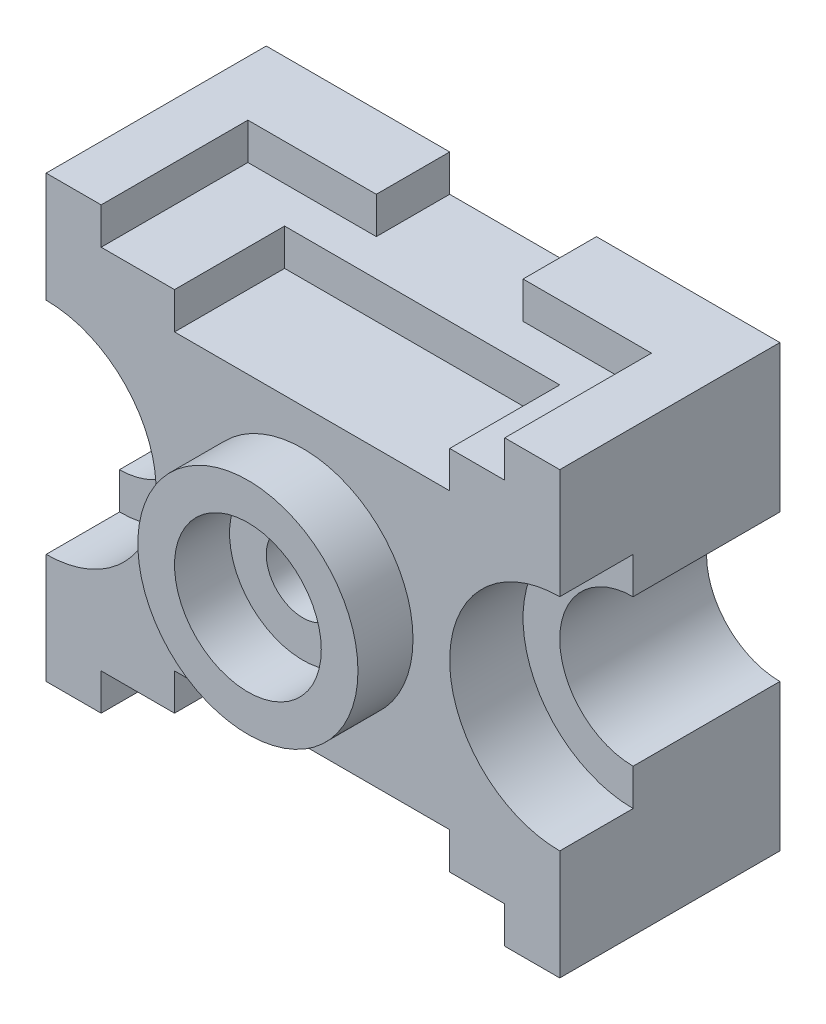
from build123d import *

# Parameters (mm, degrees)
BOSS_EXTRUDE1_DEPTH = 30
CUT_EXTRUDE7_DEPTH  = 20
SKETCH5_W           = 17.5
SKETCH5_H           = 10
BOSS_EXTRUDE2_DEPTH = 5
SKETCH6_W           = 40
SKETCH6_H           = 50
BOSS_EXTRUDE3_DEPTH = 30
SKETCH7_W           = 37.5
SKETCH7_H           = 5
CUT_EXTRUDE11_DEPTH = 15
SKETCH8_W           = 37.5
SKETCH8_H           = 5
CUT_EXTRUDE12_DEPTH = 15
CUT_EXTRUDE13_DEPTH = 10
SKETCH10_R          = 15
BOSS_EXTRUDE4_DEPTH = 7.5
SKETCH11_R          = 10
CUT_EXTRUDE14_DEPTH = 7.5
SKETCH12_R          = 5
CUT_EXTRUDE15_DEPTH = 153.5
BOSS_EXTRUDE5_DEPTH = 30
SKETCH14_W          = 17.5
SKETCH14_H          = 10
BOSS_EXTRUDE6_DEPTH = 5
CUT_EXTRUDE16_DEPTH = 20
CUT_EXTRUDE17_DEPTH = 10


with BuildPart() as part:
    # Sketch1 → Boss-Extrude1 (new body)
    with BuildSketch(Plane.XY):
        Polygon((-15, -5), (-7.5, -5), (-7.5, 0), (0, 0), (0, 50), (-7.5, 50), (-7.5, 55), (-15, 55), align=None)
    extrude(amount=BOSS_EXTRUDE1_DEPTH)

    # Sketch3 → Cut-Extrude7 (cut)
    with BuildSketch(Plane(origin=(0, 0, 0), x_dir=(-1, 0, 0), z_dir=(0, 0, -1))):
        with BuildLine():
            Line((15, 35), (15, 15))
            ThreePointArc((15, 15), (5, 25), (15, 35))
        make_face()
    extrude(amount=-CUT_EXTRUDE7_DEPTH, mode=Mode.SUBTRACT)

    # Sketch5 → Boss-Extrude2 (add)
    with BuildSketch(Plane(origin=(0, 50, 0), x_dir=(1, 0, 0), z_dir=(0, 1, 0))):
        with Locations((1.25, -5)):
            Rectangle(SKETCH5_W, SKETCH5_H)
    extrude(amount=BOSS_EXTRUDE2_DEPTH)

    # Sketch6 → Boss-Extrude3 (add)
    with BuildSketch(Plane(origin=(0, 0, 0), x_dir=(-1, 0, 0), z_dir=(0, 0, -1))):
        with Locations((-20, 25)):
            Rectangle(SKETCH6_W, SKETCH6_H)
    extrude(amount=-BOSS_EXTRUDE3_DEPTH)

    # Sketch7 → Cut-Extrude11 (cut)
    with BuildSketch(Plane.XY.offset(30)):
        with Locations((21.25, 47.5)):
            Rectangle(SKETCH7_W, SKETCH7_H)
    extrude(amount=-CUT_EXTRUDE11_DEPTH, mode=Mode.SUBTRACT)

    # Sketch8 → Cut-Extrude12 (cut)
    with BuildSketch(Plane.XY.offset(30)):
        with Locations((21.25, 2.5)):
            Rectangle(SKETCH8_W, SKETCH8_H)
    extrude(amount=-CUT_EXTRUDE12_DEPTH, mode=Mode.SUBTRACT)

    # Sketch9 → Cut-Extrude13 (cut)
    with BuildSketch(Plane.XY.offset(30)):
        with BuildLine():
            Line((-15, 10), (-15, 40))
            ThreePointArc((-15, 40), (0, 25), (-15, 10))
        make_face()
    extrude(amount=-CUT_EXTRUDE13_DEPTH, mode=Mode.SUBTRACT)

    # Sketch10 → Boss-Extrude4 (add)
    with BuildSketch(Plane.XY.offset(30)):
        with Locations((20, 25)):
            Circle(SKETCH10_R)
    extrude(amount=BOSS_EXTRUDE4_DEPTH)

    # Sketch11 → Cut-Extrude14 (cut)
    with BuildSketch(Plane.XY.offset(37.5)):
        with Locations((20, 25)):
            Circle(SKETCH11_R)
    extrude(amount=-CUT_EXTRUDE14_DEPTH, mode=Mode.SUBTRACT)

    # Sketch12 → Cut-Extrude15 (cut)
    with BuildSketch(Plane.XY.offset(30)):
        with Locations((20, 25)):
            Circle(SKETCH12_R)
    extrude(amount=-CUT_EXTRUDE15_DEPTH, mode=Mode.SUBTRACT)

    # Sketch13 → Boss-Extrude5 (add)
    with BuildSketch(Plane.XY.offset(30)):
        Polygon((55, -5), (47.5, -5), (47.5, 0), (40, 0), (40, 50), (47.5, 50), (47.5, 55), (55, 55), align=None)
    extrude(amount=-BOSS_EXTRUDE5_DEPTH)

    # Sketch14 → Boss-Extrude6 (add)
    with BuildSketch(Plane(origin=(0, 50, 0), x_dir=(1, 0, 0), z_dir=(0, 1, 0))):
        with Locations((38.75, -5)):
            Rectangle(SKETCH14_W, SKETCH14_H)
    extrude(amount=BOSS_EXTRUDE6_DEPTH)

    # Sketch15 → Cut-Extrude16 (cut)
    with BuildSketch(Plane(origin=(0, 0, 0), x_dir=(-1, 0, 0), z_dir=(0, 0, -1))):
        with BuildLine():
            Line((-55, 35), (-55, 15))
            ThreePointArc((-55, 15), (-45, 25), (-55, 35))
        make_face()
    extrude(amount=-CUT_EXTRUDE16_DEPTH, mode=Mode.SUBTRACT)

    # Sketch16 → Cut-Extrude17 (cut)
    with BuildSketch(Plane.XY.offset(30)):
        with BuildLine():
            Line((55, 10), (55, 40))
            ThreePointArc((55, 40), (40, 25), (55, 10))
        make_face()
    extrude(amount=-CUT_EXTRUDE17_DEPTH, mode=Mode.SUBTRACT)


solid = part.part
